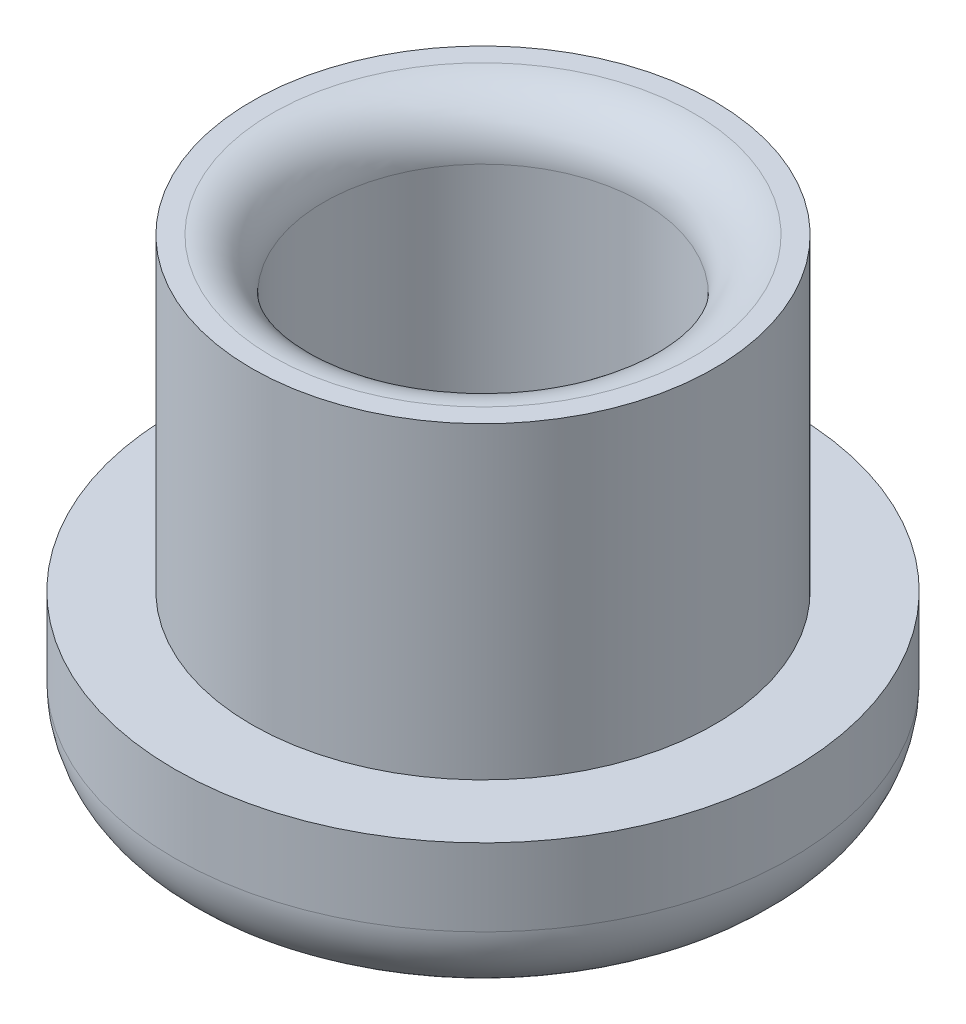
from build123d import *

# Parameters (mm, degrees)
SKETCH_1_R        = 6
EXTRUDE_1_DEPTH   = 3
SKETCH_2_R        = 4.5
SKETCH_2_R_2      = 3.1
EXTRUDE_1_2_DEPTH = 6
FILLET_1_R        = 1
FILLET_2_R        = 1.5


with BuildPart() as part:
    # ｽｹｯﾁ1 → Extrude 1 (new body)
    with BuildSketch(Plane(origin=(0, 0, 0), x_dir=(1, 0, 0), z_dir=(0, 1, 0))):
        Circle(SKETCH_1_R)
    extrude(amount=EXTRUDE_1_DEPTH)

    # ｽｹｯﾁ2 → Extrude 1 2 (add)
    with BuildSketch(Plane(origin=(0, 3, 0), x_dir=(1, 0, 0), z_dir=(0, 1, 0))):
        Circle(SKETCH_2_R)
        Circle(SKETCH_2_R_2, mode=Mode.SUBTRACT)
    extrude(amount=EXTRUDE_1_2_DEPTH)

    # ﾌｨﾚｯﾄ1
    fillet_1_edges = [part.edges().sort_by_distance(p)[0] for p in [
        (-3.1, 3, 0),
        (-3.1, 9, 0),
    ]]
    fillet(fillet_1_edges, radius=FILLET_1_R)

    # ﾌｨﾚｯﾄ2
    fillet_2_edges = [part.edges().sort_by_distance(p)[0] for p in [
        (-6, 0, 0),
    ]]
    fillet(fillet_2_edges, radius=FILLET_2_R)


solid = part.part
